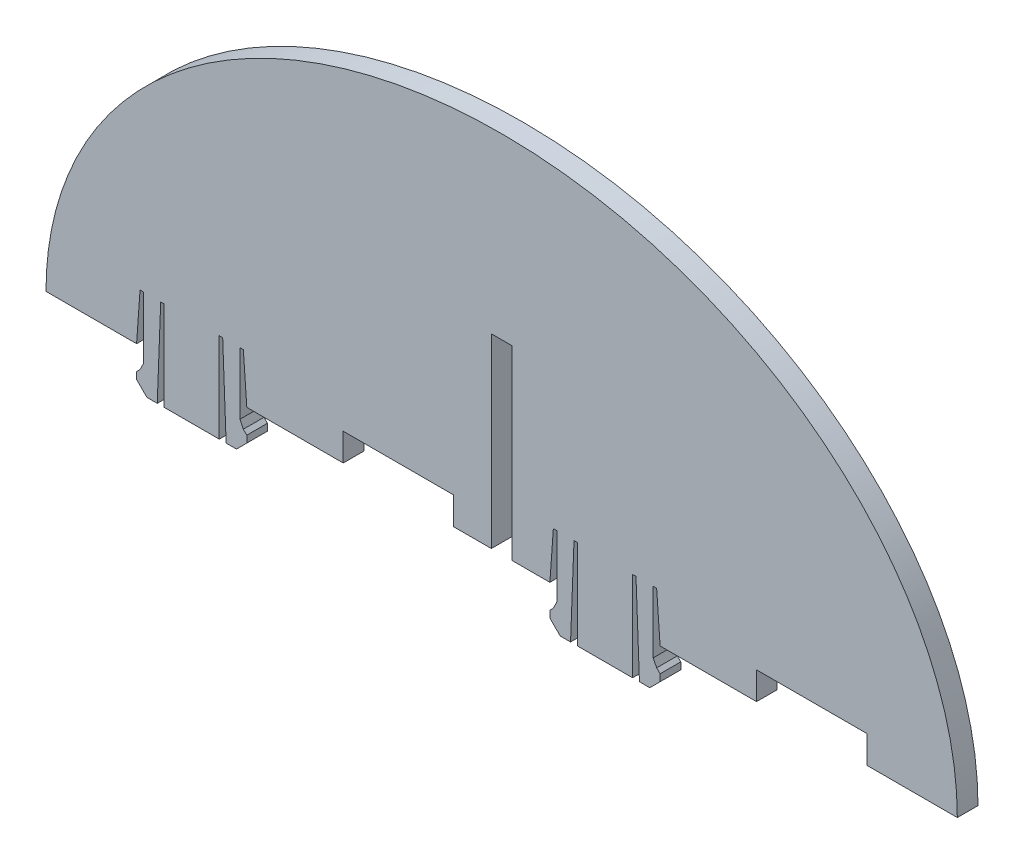
from build123d import *

# Parameters (mm, degrees)
BOSS_EXTRUDE1_DEPTH     = 3
CUT_EXTRUDE1_DEPTH      = 85.760194811
CUT_EXTRUDE1_DEPTH_BACK = 3
CUT_EXTRUDE2_DEPTH      = 85.760194811
CUT_EXTRUDE2_DEPTH_BACK = 3
CUT_EXTRUDE3_DEPTH      = 85.760194811
CUT_EXTRUDE3_DEPTH_BACK = 3


with BuildPart() as part:
    # Sketch1 → Boss-Extrude1 (new body)
    with BuildSketch(Plane.XY):
        with BuildLine():
            Line((-53, 0), (-66.15, 0))
            add(Edge.make_bspline(
                [(0, 52.91), (-66.15, 52.91), (-66.15, 0)],
                knots=[1.570796327, 1.570796327, 1.570796327, 3.141592654, 3.141592654, 3.141592654], degree=2, weights=[1, 0.707106781, 1]))
            add(Edge.make_bspline(
                [(66.15, 0), (66.15, 52.91), (0, 52.91)],
                knots=[3.141592654, 3.141592654, 3.141592654, 4.71238898, 4.71238898, 4.71238898], degree=2, weights=[1, 0.707106781, 1]))
            Line((66.15, 0), (23, 0))
            Line((23, 0), (22.5, 7.002171092))
            Line((22.5, 7.002171092), (22, 7.002171092))
            Line((22, 7.002171092), (22, -1.997828908))
            Line((22, -1.997828908), (22.5, -2.997828908))
            Line((22.5, -2.997828908), (23, -3.497828908))
            Line((23, -3.497828908), (23, -4.497828908))
            Line((23, -4.497828908), (21.5, -5.997828908))
            Line((21.5, -5.997828908), (20, -5.997828908))
            Line((20, -5.997828908), (19.5, 7.002171092))
            Line((19.5, 7.002171092), (19, 7.002171092))
            Line((19, 7.002171092), (19, -5.997828908))
            Line((19, -5.997828908), (11, -5.997828908))
            Line((11, -5.997828908), (11, 7.002171092))
            Line((11, 7.002171092), (10.5, 7.002171092))
            Line((10.5, 7.002171092), (10, -5.997828908))
            Line((10, -5.997828908), (8.5, -5.997828908))
            Line((8.5, -5.997828908), (7, -4.497828908))
            Line((7, -4.497828908), (7, -3.497828908))
            Line((7, -3.497828908), (7.5, -2.997828908))
            Line((7.5, -2.997828908), (8, -1.997828908))
            Line((8, -1.997828908), (8, 7.002171092))
            Line((8, 7.002171092), (7.5, 7.002171092))
            Line((7.5, 7.002171092), (7, 0))
            Line((7, 0), (-37, 0))
            Line((-37, 0), (-37.5, 7.002171092))
            Line((-37.5, 7.002171092), (-38, 7.002171092))
            Line((-38, 7.002171092), (-38, -1.997828908))
            Line((-38, -1.997828908), (-37.5, -2.997828908))
            Line((-37.5, -2.997828908), (-37, -3.497828908))
            Line((-37, -3.497828908), (-37, -4.497828908))
            Line((-37, -4.497828908), (-38.5, -5.997828908))
            Line((-38.5, -5.997828908), (-40, -5.997828908))
            Line((-40, -5.997828908), (-40.5, 7.002171092))
            Line((-40.5, 7.002171092), (-41, 7.002171092))
            Line((-41, 7.002171092), (-41, -5.997828908))
            Line((-41, -5.997828908), (-49, -5.997828908))
            Line((-49, -5.997828908), (-49, 7.002171092))
            Line((-49, 7.002171092), (-49.5, 7.002171092))
            Line((-49.5, 7.002171092), (-50, -5.997828908))
            Line((-50, -5.997828908), (-51.5, -5.997828908))
            Line((-51.5, -5.997828908), (-53, -4.497828908))
            Line((-53, -4.497828908), (-53, -3.497828908))
            Line((-53, -3.497828908), (-52.5, -2.997828908))
            Line((-52.5, -2.997828908), (-52, -1.997828908))
            Line((-52, -1.997828908), (-52, 7.002171092))
            Line((-52, 7.002171092), (-52.5, 7.002171092))
            Line((-52.5, 7.002171092), (-53, 0))
        make_face()
    extrude(amount=BOSS_EXTRUDE1_DEPTH)

    # Sketch2 → Cut-Extrude1 (cut, two sides)
    with BuildSketch(Plane.XY.offset(3)) as cut_extrude1_sk:
        Polygon((-1.5, -181.767175259), (-1.5, 0), (-1.5, 27), (1.5, 27), (1.5, 0), (1.5, -181.767175259), (1.5, -545.301525777), (-1.5, -545.301525777), align=None)
    extrude(amount=CUT_EXTRUDE1_DEPTH, mode=Mode.SUBTRACT)
    extrude(cut_extrude1_sk.sketch, amount=-CUT_EXTRUDE1_DEPTH_BACK, mode=Mode.SUBTRACT)

    # Sketch3 → Cut-Extrude2 (cut, two sides)
    with BuildSketch(Plane.XY.offset(3)) as cut_extrude2_sk:
        Polygon((-23, -217.337315777), (-23, 0), (-23, 4), (-7, 4), (-7, 0), (-7, -217.337315777), (-7, -652.011947331), (-23, -652.011947331), align=None)
    extrude(amount=CUT_EXTRUDE2_DEPTH, mode=Mode.SUBTRACT)
    extrude(cut_extrude2_sk.sketch, amount=-CUT_EXTRUDE2_DEPTH_BACK, mode=Mode.SUBTRACT)

    # Sketch4 → Cut-Extrude3 (cut, two sides)
    with BuildSketch(Plane.XY.offset(3)) as cut_extrude3_sk:
        Polygon((37, -270.738878071), (37, 0), (37, 4), (53, 4), (53, 0), (53, -270.738878071), (53, -812.216634213), (37, -812.216634213), align=None)
    extrude(amount=CUT_EXTRUDE3_DEPTH, mode=Mode.SUBTRACT)
    extrude(cut_extrude3_sk.sketch, amount=-CUT_EXTRUDE3_DEPTH_BACK, mode=Mode.SUBTRACT)


solid = part.part
